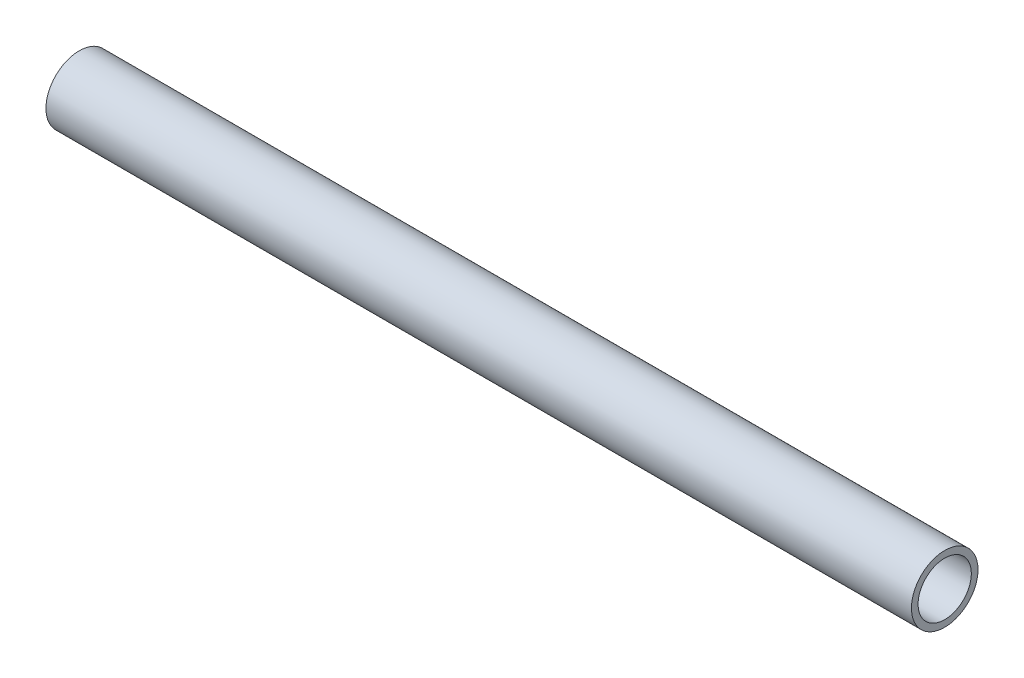
from build123d import *

# Parameters (mm, degrees)
SKETCH11_R            = 12.7
SKETCH11_R_2          = 10.16
TUBING_TUBING_1_DEPTH = 330.2


with BuildPart() as part:
    # Sketch11 → Tubing TUBING(1) (new body)
    with BuildSketch(Plane.YZ):
        Circle(SKETCH11_R)
        Circle(SKETCH11_R_2, mode=Mode.SUBTRACT)
    extrude(amount=TUBING_TUBING_1_DEPTH)


solid = part.part
